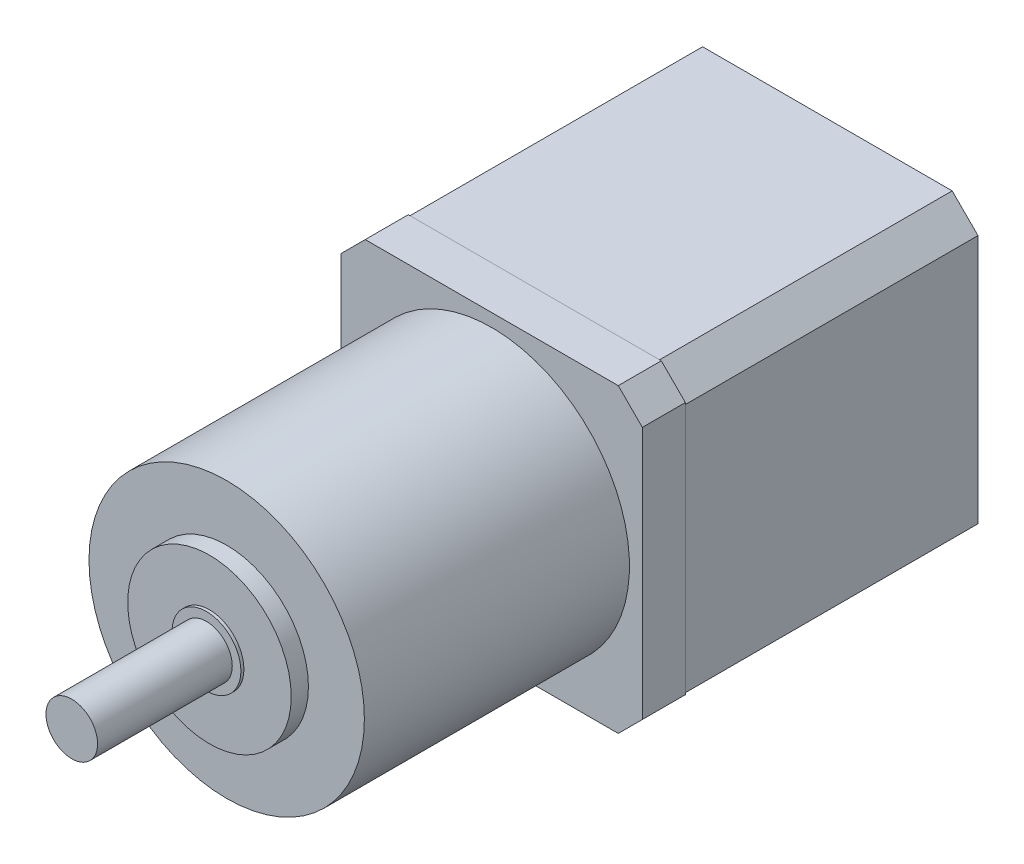
from build123d import *

# Parameters (mm, degrees)
SKETCH1_W           = 35
SKETCH1_H           = 35
BOSS_EXTRUDE1_DEPTH = 34
CHAMFER1_SIZE       = 3
SKETCH2_W           = 35
SKETCH2_H           = 35
BOSS_EXTRUDE2_DEPTH = 5
CHAMFER2_SIZE       = 2.8
SKETCH3_R           = 16
BOSS_EXTRUDE3_DEPTH = 30.8
SKETCH4_R           = 9.5
BOSS_EXTRUDE4_DEPTH = 2
SKETCH6_R           = 3
BOSS_EXTRUDE5_DEPTH = 18
SKETCH7_R           = 4
BOSS_EXTRUDE6_DEPTH = 0.35


with BuildPart() as part:
    # Sketch1 → Boss-Extrude1 (new body)
    with BuildSketch(Plane.XY):
        Rectangle(SKETCH1_W, SKETCH1_H)
    extrude(amount=BOSS_EXTRUDE1_DEPTH)

    # Chamfer1
    chamfer1_edges = [part.edges().sort_by_distance(p)[0] for p in [
        (17.5, -17.5, 17),
        (-17.5, -17.5, 17),
        (-17.5, 17.5, 17),
        (17.5, 17.5, 17),
    ]]
    chamfer(chamfer1_edges, length=CHAMFER1_SIZE)


with BuildPart() as body_2:
    # Sketch2 → Boss-Extrude2 (new body)
    with BuildSketch(Plane.XY.offset(34)):
        Rectangle(SKETCH2_W, SKETCH2_H)
    extrude(amount=BOSS_EXTRUDE2_DEPTH)

    # Chamfer2
    chamfer2_edges = [body_2.edges().sort_by_distance(p)[0] for p in [
        (17.5, -17.5, 36.5),
        (-17.5, -17.5, 36.5),
        (-17.5, 17.5, 36.5),
        (17.5, 17.5, 36.5),
    ]]
    chamfer(chamfer2_edges, length=CHAMFER2_SIZE)

    # Sketch3 → Boss-Extrude3 (add)
    with BuildSketch(Plane.XY.offset(39)):
        Circle(SKETCH3_R)
    extrude(amount=BOSS_EXTRUDE3_DEPTH)

    # Sketch4 → Boss-Extrude4 (add)
    with BuildSketch(Plane.XY.offset(69.8)):
        Circle(SKETCH4_R)
    extrude(amount=BOSS_EXTRUDE4_DEPTH)

    # Sketch6 → Boss-Extrude5 (add)
    with BuildSketch(Plane.XY.offset(69.8)):
        Circle(SKETCH6_R)
    extrude(amount=BOSS_EXTRUDE5_DEPTH)

    # Sketch7 → Boss-Extrude6 (add)
    with BuildSketch(Plane.XY.offset(71.8)):
        Circle(SKETCH7_R)
    extrude(amount=BOSS_EXTRUDE6_DEPTH)


solid = Compound([part.part, body_2.part])
